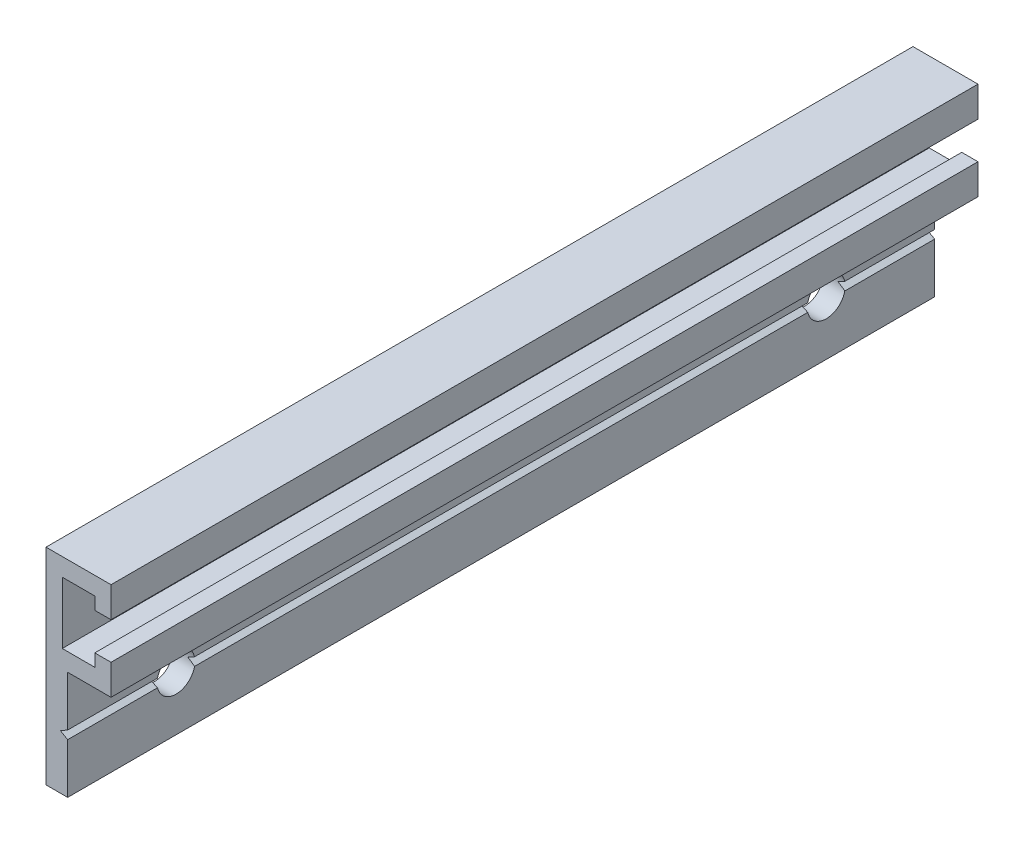
from build123d import *

# Parameters (mm, degrees)
BOSS_EXTRUDE1_DEPTH        = 80
F_3_5_3_5_DIAMETER_HOLE1_D = 3.5


with BuildPart() as part:
    # Sketch1 → Boss-Extrude1 (new body)
    with BuildSketch(Plane.XY):
        Polygon((6, -2.8), (6, 0), (0, 0), (0, -19), (2, -19), (2, -14.384515279), (1.334, -14), (2, -13.615484721), (2, -9), (6, -9), (6, -6.2), (4.5, -6.2), (4.5, -7.35), (1.5, -7.35), (1.5, -1.65), (4.5, -1.65), (4.5, -2.8), align=None)
    extrude(amount=-BOSS_EXTRUDE1_DEPTH)

    # Ø3.5 (3.5) Diameter Hole1 (through all)
    with Locations(Plane.ZY):
        with Locations((-10, -14), (-70, -14)):
            Hole(F_3_5_3_5_DIAMETER_HOLE1_D / 2)


solid = part.part
